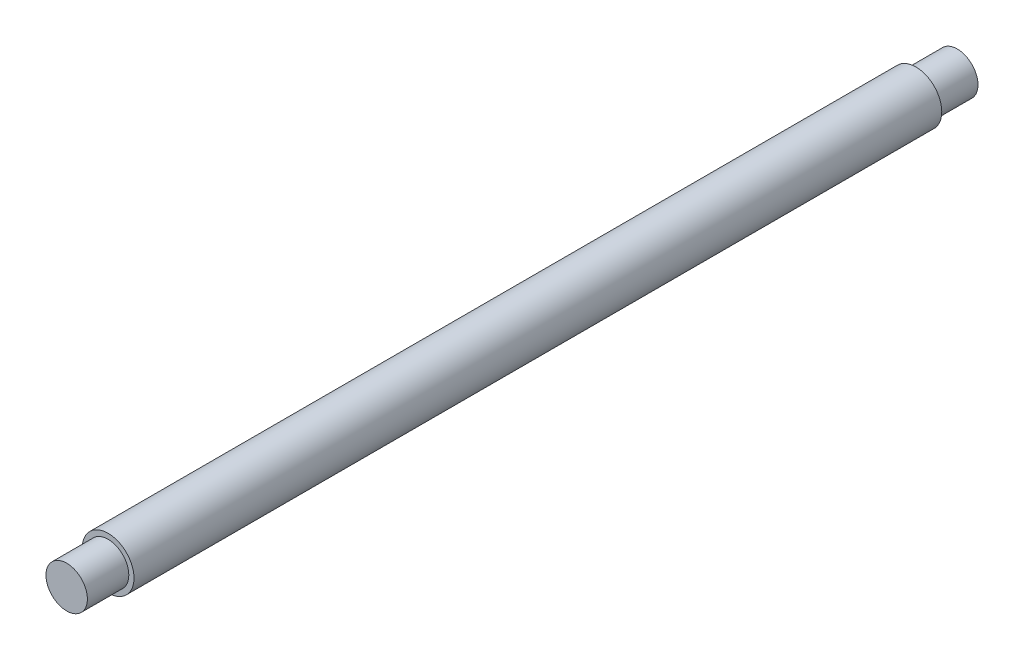
from build123d import *

# Parameters (mm, degrees)
SKETCH2_R           = 5
BOSS_EXTRUDE1_DEPTH = 78
SKETCH4_R           = 4
BOSS_EXTRUDE3_DEPTH = 8


with BuildPart() as part:
    # Sketch2 → Boss-Extrude1 (new body, symmetric)
    with BuildSketch(Plane.XY):
        Circle(SKETCH2_R)
    extrude(amount=BOSS_EXTRUDE1_DEPTH, both=True)

    # Sketch4 → Boss-Extrude3 (add)
    with BuildSketch(Plane.XY.offset(78)):
        Circle(SKETCH4_R)
    boss_extrude3 = extrude(amount=BOSS_EXTRUDE3_DEPTH)

    # Mirror1: Boss-Extrude3 across plane
    add(boss_extrude3.mirror(Plane.XY))


solid = part.part
